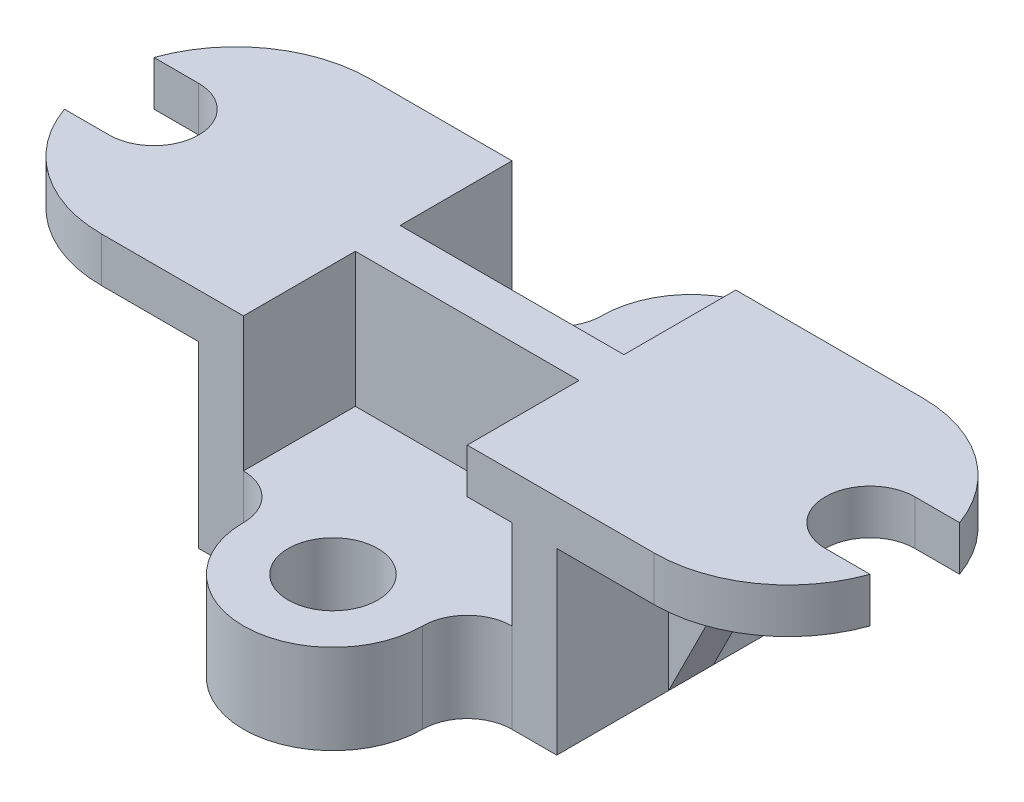
from build123d import *

# Parameters (mm, degrees)
SKETCH1_W           = 180
SKETCH1_H           = 60
BOSS_EXTRUDE1_DEPTH = 10
CUT_EXTRUDE1_DEPTH  = 10
SKETCH3_W           = 10
SKETCH3_H           = 60
BOSS_EXTRUDE2_DEPTH = 40
SKETCH4_W           = 10
SKETCH4_H           = 40
BOSS_EXTRUDE3_DEPTH = 20
CUT_EXTRUDE2_DEPTH  = 20
SKETCH6_W           = 10
SKETCH6_H           = 40
BOSS_EXTRUDE4_DEPTH = 20
CUT_EXTRUDE3_DEPTH  = 20
BOSS_EXTRUDE5_DEPTH = 20
SKETCH10_R          = 10
CUT_EXTRUDE4_DEPTH  = 20
SKETCH11_W          = 50
SKETCH11_H          = 25
CUT_EXTRUDE5_DEPTH  = 20
SKETCH12_W          = 60
SKETCH12_H          = 20
BOSS_EXTRUDE6_DEPTH = 10


with BuildPart() as part:
    # Sketch1 → Boss-Extrude1 (new body)
    with BuildSketch(Plane(origin=(0, 0, 0), x_dir=(1, 0, 0), z_dir=(0, 1, 0))):
        with Locations((90, 30)):
            Rectangle(SKETCH1_W, SKETCH1_H)
    extrude(amount=BOSS_EXTRUDE1_DEPTH)

    # Sketch2 → Cut-Extrude1 (cut)
    with BuildSketch(Plane(origin=(0, 10, 0), x_dir=(1, 0, 0), z_dir=(0, 1, 0))):
        with BuildLine():
            Line((0, 60), (0, 40))
            ThreePointArc((0, 40), (10.963763172, 54.494897428), (28.284271247, 60))
            Line((28.284271247, 60), (0, 60))
        make_face()
        with BuildLine():
            Line((10, 40), (0, 40))
            Line((0, 40), (0, 20))
            Line((0, 20), (10, 20))
            ThreePointArc((10, 20), (20, 30), (10, 40))
        make_face()
        with BuildLine():
            ThreePointArc((28.284271247, 0), (10.963763172, 5.505102572), (0, 20))
            Line((0, 20), (0, 0))
            Line((0, 0), (28.284271247, 0))
        make_face()
        with BuildLine():
            ThreePointArc((180, 20), (169.036236828, 5.505102572), (151.715728753, 0))
            Line((151.715728753, 0), (180, 0))
            Line((180, 0), (180, 20))
        make_face()
        with BuildLine():
            Line((180, 20), (180, 40))
            Line((180, 40), (170, 40))
            ThreePointArc((170, 40), (160, 30), (170, 20))
            Line((170, 20), (180, 20))
        make_face()
        with BuildLine():
            Line((180, 60), (151.715728753, 60))
            ThreePointArc((151.715728753, 60), (169.036236828, 54.494897428), (180, 40))
            Line((180, 40), (180, 60))
        make_face()
    extrude(amount=-CUT_EXTRUDE1_DEPTH, mode=Mode.SUBTRACT)

    # Sketch3 → Boss-Extrude2 (add)
    with BuildSketch(Plane(origin=(0, 0, 0), x_dir=(-1, 0, 0), z_dir=(0, -1, 0))):
        with Locations((-55, 30)):
            Rectangle(SKETCH3_W, SKETCH3_H)
        with Locations((-125, 30)):
            Rectangle(SKETCH3_W, SKETCH3_H)
    extrude(amount=BOSS_EXTRUDE2_DEPTH)

    # Sketch4 → Boss-Extrude3 (add)
    with BuildSketch(Plane.ZY.offset(-50)):
        with Locations((-30, -20)):
            Rectangle(SKETCH4_W, SKETCH4_H)
    extrude(amount=BOSS_EXTRUDE3_DEPTH)

    # Sketch5 → Cut-Extrude2 (cut)
    with BuildSketch(Plane.XY.offset(-25)):
        Polygon((30, 0), (50, -40), (30, -40), align=None)
    extrude(amount=-CUT_EXTRUDE2_DEPTH, mode=Mode.SUBTRACT)

    # Sketch6 → Boss-Extrude4 (add)
    with BuildSketch(Plane(origin=(130, 0, 0), x_dir=(0, 0, -1), z_dir=(1, 0, 0))):
        with Locations((30, -20)):
            Rectangle(SKETCH6_W, SKETCH6_H)
    extrude(amount=BOSS_EXTRUDE4_DEPTH)

    # Sketch7 → Cut-Extrude3 (cut)
    with BuildSketch(Plane.XY.offset(-25)):
        Polygon((130, -40), (150, 0), (150, -40), align=None)
    extrude(amount=-CUT_EXTRUDE3_DEPTH, mode=Mode.SUBTRACT)

    # Sketch9 → Boss-Extrude5 (add)
    with BuildSketch(Plane.XZ.offset(40)):
        with BuildLine():
            Line((60, 0), (60, -60))
            ThreePointArc((60, -60), (67.071067812, -62.928932188), (70, -70))
            ThreePointArc((70, -70), (90, -90), (110, -70))
            ThreePointArc((110, -70), (112.928932188, -62.928932188), (120, -60))
            Line((120, -60), (120, 0))
            ThreePointArc((120, 0), (112.928932188, 2.928932188), (110, 10))
            ThreePointArc((110, 10), (90, 30), (70, 10))
            ThreePointArc((70, 10), (67.071067812, 2.928932188), (60, 0))
        make_face()
    extrude(amount=-BOSS_EXTRUDE5_DEPTH)

    # Sketch10 → Cut-Extrude4 (cut)
    with BuildSketch(Plane(origin=(0, -20, 0), x_dir=(1, 0, 0), z_dir=(0, 1, 0))):
        with Locations((90, 70)):
            Circle(SKETCH10_R)
        with Locations((90, -10)):
            Circle(SKETCH10_R)
    extrude(amount=-CUT_EXTRUDE4_DEPTH, mode=Mode.SUBTRACT)

    # Sketch11 → Cut-Extrude5 (cut)
    with BuildSketch(Plane(origin=(0, 10, 0), x_dir=(1, 0, 0), z_dir=(0, 1, 0))):
        with Locations((85, 47.5)):
            Rectangle(SKETCH11_W, SKETCH11_H)
        with Locations((85, 12.5)):
            Rectangle(SKETCH11_W, SKETCH11_H)
    extrude(amount=-CUT_EXTRUDE5_DEPTH, mode=Mode.SUBTRACT)

    # Sketch12 → Boss-Extrude6 (add)
    with BuildSketch(Plane.XY.offset(-25)):
        with Locations((90, -10)):
            Rectangle(SKETCH12_W, SKETCH12_H)
    extrude(amount=-BOSS_EXTRUDE6_DEPTH)


solid = part.part
